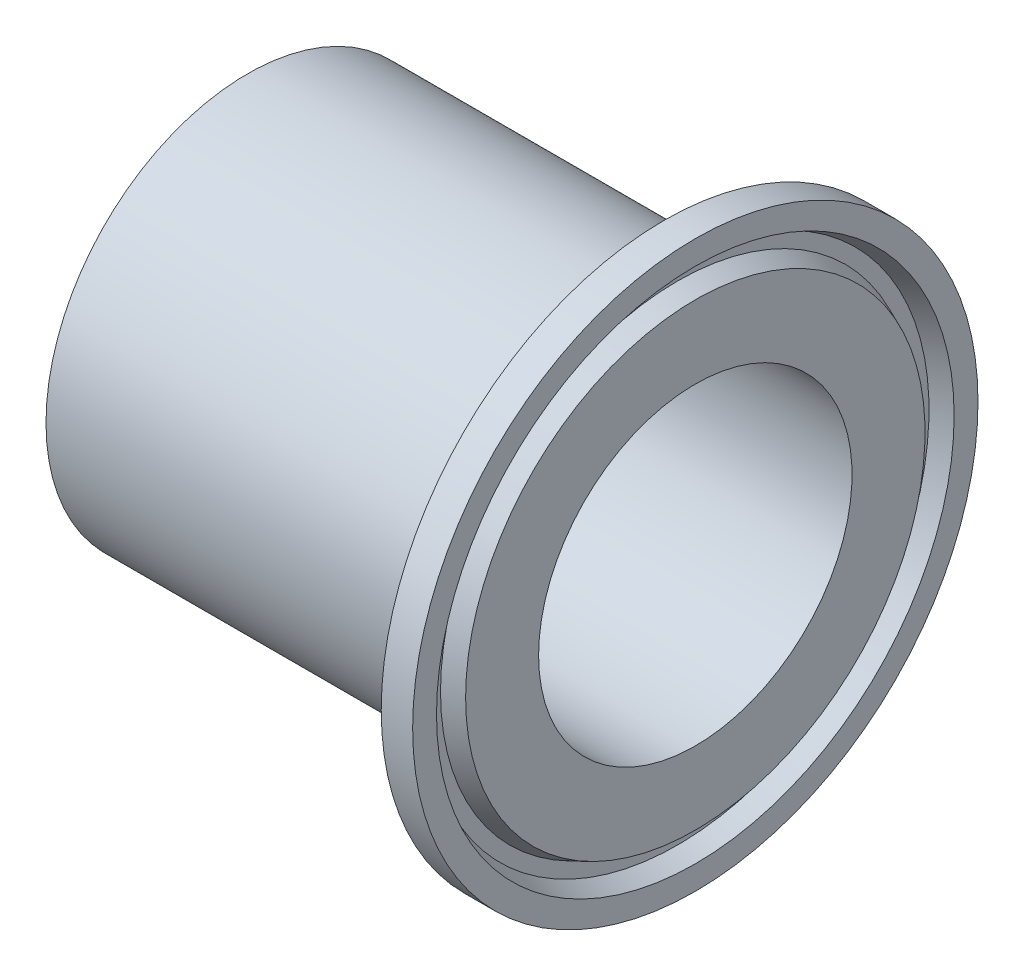
from build123d import *

# Parameters (mm, degrees)
CHAMFER1_SIZE      = 2
SKETCH7_R          = 14
CUT_EXTRUDE2_DEPTH = 54.620192092


with BuildPart() as part:
    # Sketch1 → Revolve1 (revolve)
    with BuildSketch(Plane.XY):
        Polygon((34.554515802, 18), (37.1933, 25.25), (40, 25.25), (40, 23.1186), (38.4252, 22.450137059), (38.4252, 21.187062941), (40, 20.5186), (40, 14), (40, 12), (35, 12), (35, 14), (0, 14), (0, 18), align=None)
    revolve(axis=Axis((0, 0, 0), (1, 0, 0)))

    # Chamfer1
    chamfer1_edges = [part.edges().sort_by_distance(p)[0] for p in [
        (0, -14, 0),
    ]]
    chamfer(chamfer1_edges, length=CHAMFER1_SIZE)

    # Sketch7 → Cut-Extrude2 (cut, through all)
    with BuildSketch(Plane.ZY):
        Circle(SKETCH7_R)
    extrude(amount=-CUT_EXTRUDE2_DEPTH, mode=Mode.SUBTRACT)


solid = part.part
